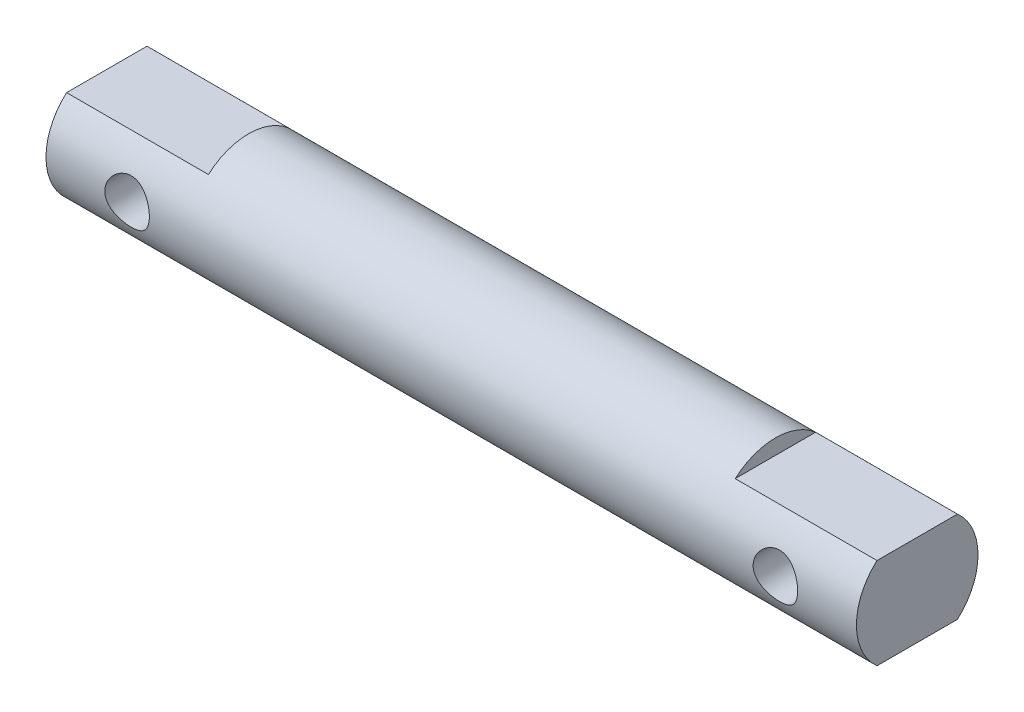
from build123d import *

# Parameters (mm, degrees)
SKETCH1_W               = 40
SKETCH1_H               = 3
SKETCH2_W               = 7
SKETCH2_H               = 0.75
CUT_EXTRUDE1_DEPTH      = 4
CUT_EXTRUDE1_DEPTH_BACK = 4
SKETCH3_R               = 1.1
CUT_EXTRUDE2_DEPTH      = 4
CUT_EXTRUDE2_DEPTH_BACK = 4


with BuildPart() as part:
    # Sketch1 → Revolve1 (revolve)
    with BuildSketch(Plane.XY):
        with Locations((0, 1.5)):
            Rectangle(SKETCH1_W, SKETCH1_H)
    revolve(axis=Axis((0, 0, 0), (1, 0, 0)))

    # Sketch2 → Cut-Extrude1 (cut, two sides)
    with BuildSketch(Plane.XY) as cut_extrude1_sk:
        with Locations((-16.5, 2.625)):
            Rectangle(SKETCH2_W, SKETCH2_H)
        with Locations((-16.5, -2.625)):
            Rectangle(SKETCH2_W, SKETCH2_H)
        with Locations((16.5, 2.625)):
            Rectangle(SKETCH2_W, SKETCH2_H)
        with Locations((16.5, -2.625)):
            Rectangle(SKETCH2_W, SKETCH2_H)
    extrude(amount=CUT_EXTRUDE1_DEPTH, mode=Mode.SUBTRACT)
    extrude(cut_extrude1_sk.sketch, amount=-CUT_EXTRUDE1_DEPTH_BACK, mode=Mode.SUBTRACT)

    # Sketch3 → Cut-Extrude2 (cut, two sides)
    with BuildSketch(Plane.XY) as cut_extrude2_sk:
        with Locations((-16, 0)):
            Circle(SKETCH3_R)
        with Locations((16, 0)):
            Circle(SKETCH3_R)
    extrude(amount=CUT_EXTRUDE2_DEPTH, mode=Mode.SUBTRACT)
    extrude(cut_extrude2_sk.sketch, amount=-CUT_EXTRUDE2_DEPTH_BACK, mode=Mode.SUBTRACT)


solid = part.part
